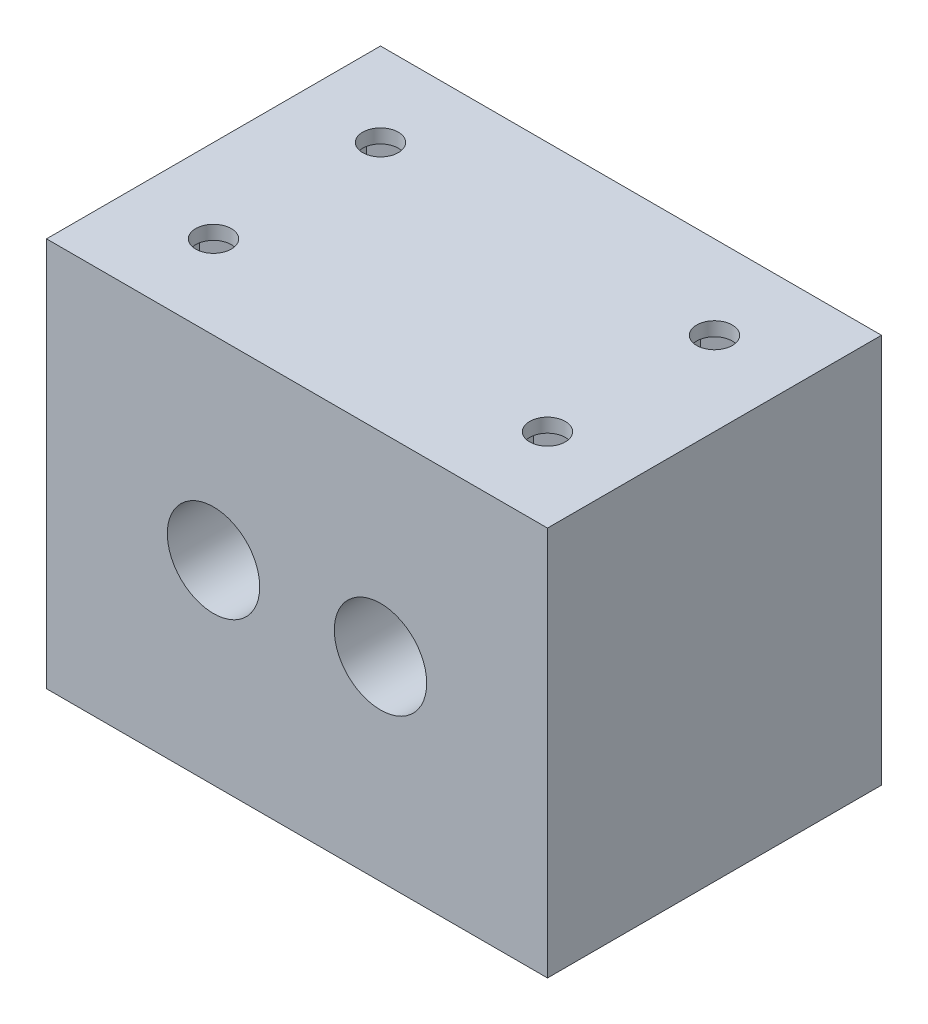
from build123d import *

# Parameters (mm, degrees)
SKETCH1_W           = 15
SKETCH1_H           = 30
SKETCH1_R           = 1.6
BOSS_EXTRUDE1_DEPTH = 5
CUT_EXTRUDE1_START  = 1.25
SKETCH1_3_R         = 1.6
CUT_EXTRUDE1_DEPTH  = 2.5
BOSS_EXTRUDE2_START = 5
SKETCH1_4_W         = 15
SKETCH1_4_H         = 30
SKETCH1_4_R         = 1.6
BOSS_EXTRUDE2_DEPTH = 30
SKETCH5_R           = 4.15
CUT_EXTRUDE2_DEPTH  = 52.295711322
CUT_EXTRUDE3_START  = -1.25
CUT_EXTRUDE3_DEPTH  = 2.5


with BuildPart() as part:
    # Sketch1 → Boss-Extrude1 (new body)
    with BuildSketch(Plane(origin=(0, 0, 0), x_dir=(1, 0, 0), z_dir=(0, 1, 0))):
        with Locations((-15, 0)):
            Rectangle(SKETCH1_W, SKETCH1_H)
        Polygon((-12.025, -5.782382949), (-15, -4.064765898), (-17.975, -5.782382949), (-17.975, -9.217617051), (-15, -10.935234102), (-12.025, -9.217617051), align=None, mode=Mode.SUBTRACT)
        Polygon((-12.025, 9.217617051), (-15, 10.935234102), (-17.975, 9.217617051), (-17.975, 5.782382949), (-15, 4.064765898), (-12.025, 5.782382949), align=None, mode=Mode.SUBTRACT)
        Rectangle(SKETCH1_W, SKETCH1_H)
        with Locations((15, 0)):
            Rectangle(SKETCH1_W, SKETCH1_H)
        Polygon((17.975, -5.782382949), (15, -4.064765898), (12.025, -5.782382949), (12.025, -9.217617051), (15, -10.935234102), (17.975, -9.217617051), align=None, mode=Mode.SUBTRACT)
        Polygon((17.975, 9.217617051), (15, 10.935234102), (12.025, 9.217617051), (12.025, 5.782382949), (15, 4.064765898), (17.975, 5.782382949), align=None, mode=Mode.SUBTRACT)
        Polygon((-12.025, -9.217617051), (-12.025, -5.782382949), (-15, -4.064765898), (-17.975, -5.782382949), (-17.975, -9.217617051), (-15, -10.935234102), align=None)
        with Locations(Location((-15, -7.5, 0), (0, 0, 270))):
            Circle(SKETCH1_R, mode=Mode.SUBTRACT)
        Polygon((-12.025, 5.782382949), (-12.025, 9.217617051), (-15, 10.935234102), (-17.975, 9.217617051), (-17.975, 5.782382949), (-15, 4.064765898), align=None)
        with Locations(Location((-15, 7.5, 0), (0, 0, 270))):
            Circle(SKETCH1_R, mode=Mode.SUBTRACT)
        Polygon((17.975, 5.782382949), (17.975, 9.217617051), (15, 10.935234102), (12.025, 9.217617051), (12.025, 5.782382949), (15, 4.064765898), align=None)
        with Locations(Location((15, 7.5, 0), (0, 0, 270))):
            Circle(SKETCH1_R, mode=Mode.SUBTRACT)
        Polygon((17.975, -9.217617051), (17.975, -5.782382949), (15, -4.064765898), (12.025, -5.782382949), (12.025, -9.217617051), (15, -10.935234102), align=None)
        with Locations(Location((15, -7.5, 0), (0, 0, 270))):
            Circle(SKETCH1_R, mode=Mode.SUBTRACT)
    extrude(amount=BOSS_EXTRUDE1_DEPTH)

    # Sketch1_3 → Cut-Extrude1 (cut)
    with BuildSketch(Plane(origin=(0, 0, 0), x_dir=(1, 0, 0), z_dir=(0, 1, 0)).offset(CUT_EXTRUDE1_START)):
        Polygon((-12.025, 5.782382949), (-12.025, 9.217617051), (-15, 10.935234102), (-17.975, 9.217617051), (-17.975, 5.782382949), (-15, 4.064765898), align=None)
        with Locations(Location((-15, 7.5, 0), (0, 0, 270))):
            Circle(SKETCH1_3_R, mode=Mode.SUBTRACT)
        Polygon((-12.025, -9.217617051), (-12.025, -5.782382949), (-15, -4.064765898), (-17.975, -5.782382949), (-17.975, -9.217617051), (-15, -10.935234102), align=None)
        with Locations(Location((-15, -7.5, 0), (0, 0, 270))):
            Circle(SKETCH1_3_R, mode=Mode.SUBTRACT)
        Polygon((17.975, -9.217617051), (17.975, -5.782382949), (15, -4.064765898), (12.025, -5.782382949), (12.025, -9.217617051), (15, -10.935234102), align=None)
        with Locations(Location((15, -7.5, 0), (0, 0, 270))):
            Circle(SKETCH1_3_R, mode=Mode.SUBTRACT)
        Polygon((17.975, 5.782382949), (17.975, 9.217617051), (15, 10.935234102), (12.025, 9.217617051), (12.025, 5.782382949), (15, 4.064765898), align=None)
        with Locations(Location((15, 7.5, 0), (0, 0, 270))):
            Circle(SKETCH1_3_R, mode=Mode.SUBTRACT)
    extrude(amount=CUT_EXTRUDE1_DEPTH, mode=Mode.SUBTRACT)

    # Sketch1_4 → Boss-Extrude2 (add)
    with BuildSketch(Plane(origin=(0, 0, 0), x_dir=(1, 0, 0), z_dir=(0, 1, 0)).offset(BOSS_EXTRUDE2_START)):
        Rectangle(SKETCH1_4_W, SKETCH1_4_H)
        with Locations((-15, 0)):
            Rectangle(SKETCH1_4_W, SKETCH1_4_H)
        Polygon((-12.025, -5.782382949), (-15, -4.064765898), (-17.975, -5.782382949), (-17.975, -9.217617051), (-15, -10.935234102), (-12.025, -9.217617051), align=None, mode=Mode.SUBTRACT)
        Polygon((-12.025, 9.217617051), (-15, 10.935234102), (-17.975, 9.217617051), (-17.975, 5.782382949), (-15, 4.064765898), (-12.025, 5.782382949), align=None, mode=Mode.SUBTRACT)
        Polygon((-12.025, -9.217617051), (-12.025, -5.782382949), (-15, -4.064765898), (-17.975, -5.782382949), (-17.975, -9.217617051), (-15, -10.935234102), align=None)
        with Locations(Location((-15, -7.5, 0), (0, 0, 270))):
            Circle(SKETCH1_4_R, mode=Mode.SUBTRACT)
        Polygon((-12.025, 5.782382949), (-12.025, 9.217617051), (-15, 10.935234102), (-17.975, 9.217617051), (-17.975, 5.782382949), (-15, 4.064765898), align=None)
        with Locations(Location((-15, 7.5, 0), (0, 0, 270))):
            Circle(SKETCH1_4_R, mode=Mode.SUBTRACT)
        with Locations((15, 0)):
            Rectangle(SKETCH1_4_W, SKETCH1_4_H)
        Polygon((17.975, -5.782382949), (15, -4.064765898), (12.025, -5.782382949), (12.025, -9.217617051), (15, -10.935234102), (17.975, -9.217617051), align=None, mode=Mode.SUBTRACT)
        Polygon((17.975, 9.217617051), (15, 10.935234102), (12.025, 9.217617051), (12.025, 5.782382949), (15, 4.064765898), (17.975, 5.782382949), align=None, mode=Mode.SUBTRACT)
        Polygon((17.975, -9.217617051), (17.975, -5.782382949), (15, -4.064765898), (12.025, -5.782382949), (12.025, -9.217617051), (15, -10.935234102), align=None)
        with Locations(Location((15, -7.5, 0), (0, 0, 270))):
            Circle(SKETCH1_4_R, mode=Mode.SUBTRACT)
        Polygon((17.975, 5.782382949), (17.975, 9.217617051), (15, 10.935234102), (12.025, 9.217617051), (12.025, 5.782382949), (15, 4.064765898), align=None)
        with Locations(Location((15, 7.5, 0), (0, 0, 270))):
            Circle(SKETCH1_4_R, mode=Mode.SUBTRACT)
    extrude(amount=BOSS_EXTRUDE2_DEPTH)

    # Sketch5 → Cut-Extrude2 (cut, through all)
    with BuildSketch(Plane.XY.offset(15)):
        with Locations((-7.5, 17.5)):
            Circle(SKETCH5_R)
        with Locations((7.5, 17.5)):
            Circle(SKETCH5_R)
    extrude(amount=-CUT_EXTRUDE2_DEPTH, mode=Mode.SUBTRACT)

    # Sketch6 → Cut-Extrude3 (cut)
    with BuildSketch(Plane(origin=(0, 35, 0), x_dir=(1, 0, 0), z_dir=(0, 1, 0)).offset(CUT_EXTRUDE3_START)):
        Polygon((-15, 10.935234102), (-17.975, 9.217617051), (-17.975, 5.782382949), (-15, 4.064765898), (-12.025, 5.782382949), (-12.025, 9.217617051), align=None)
        Polygon((15, 10.935234102), (12.025, 9.217617051), (12.025, 5.782382949), (15, 4.064765898), (17.975, 5.782382949), (17.975, 9.217617051), align=None)
        Polygon((15, -4.064765898), (12.025, -5.782382949), (12.025, -9.217617051), (15, -10.935234102), (17.975, -9.217617051), (17.975, -5.782382949), align=None)
        Polygon((-15, -4.064765898), (-17.975, -5.782382949), (-17.975, -9.217617051), (-15, -10.935234102), (-12.025, -9.217617051), (-12.025, -5.782382949), align=None)
    extrude(amount=-CUT_EXTRUDE3_DEPTH, mode=Mode.SUBTRACT)


solid = part.part
